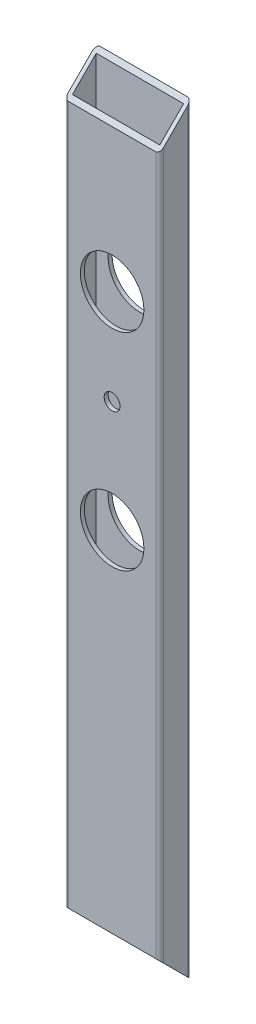
from build123d import *

# Parameters (mm, degrees)
SKETCH1_W           = 34.925
SKETCH1_H           = 9.525
BOSS_EXTRUDE1_DEPTH = 304.8
SKETCH2_R           = 12.7
SKETCH2_R_2         = 3.175
CUT_EXTRUDE1_DEPTH  = 13.7
CUT_EXTRUDE2_DEPTH  = 39.1


with BuildPart() as part:
    # Sketch1 → Boss-Extrude1 (new body)
    with BuildSketch(Plane(origin=(0, 0, 0), x_dir=(1, 0, 0), z_dir=(0, 1, 0))):
        with BuildLine():
            Line((1.5875, 0), (36.5125, 0))
            ThreePointArc((36.5125, 0), (37.635032015, 0.464967985), (38.1, 1.5875))
            Line((38.1, 1.5875), (38.1, 11.1125))
            ThreePointArc((38.1, 11.1125), (37.635032015, 12.235032015), (36.5125, 12.7))
            Line((36.5125, 12.7), (1.5875, 12.7))
            ThreePointArc((1.5875, 12.7), (0.464967985, 12.235032015), (0, 11.1125))
            Line((0, 11.1125), (0, 1.5875))
            ThreePointArc((0, 1.5875), (0.464967985, 0.464967985), (1.5875, 0))
        make_face()
        with Locations((19.05, 6.35)):
            Rectangle(SKETCH1_W, SKETCH1_H, mode=Mode.SUBTRACT)
    extrude(amount=BOSS_EXTRUDE1_DEPTH)

    # Sketch2 → Cut-Extrude1 (cut, through all)
    with BuildSketch(Plane.XY):
        with Locations((19.05, 152.4)):
            Circle(SKETCH2_R)
        with Locations((19.05, 196.85)):
            Circle(SKETCH2_R_2)
        with Locations((19.05, 234.95)):
            Circle(SKETCH2_R)
    extrude(amount=-CUT_EXTRUDE1_DEPTH, mode=Mode.SUBTRACT)

    # Sketch3 → Cut-Extrude2 (cut, through all)
    with BuildSketch(Plane(origin=(38.1, 0, 0), x_dir=(0, 0, -1), z_dir=(1, 0, 0))):
        Polygon((0, 0), (12.7, 0), (0, 12.7), align=None)
        Polygon((0, 304.8), (12.7, 304.8), (0, 292.1), align=None)
    extrude(amount=-CUT_EXTRUDE2_DEPTH, mode=Mode.SUBTRACT)


solid = part.part
